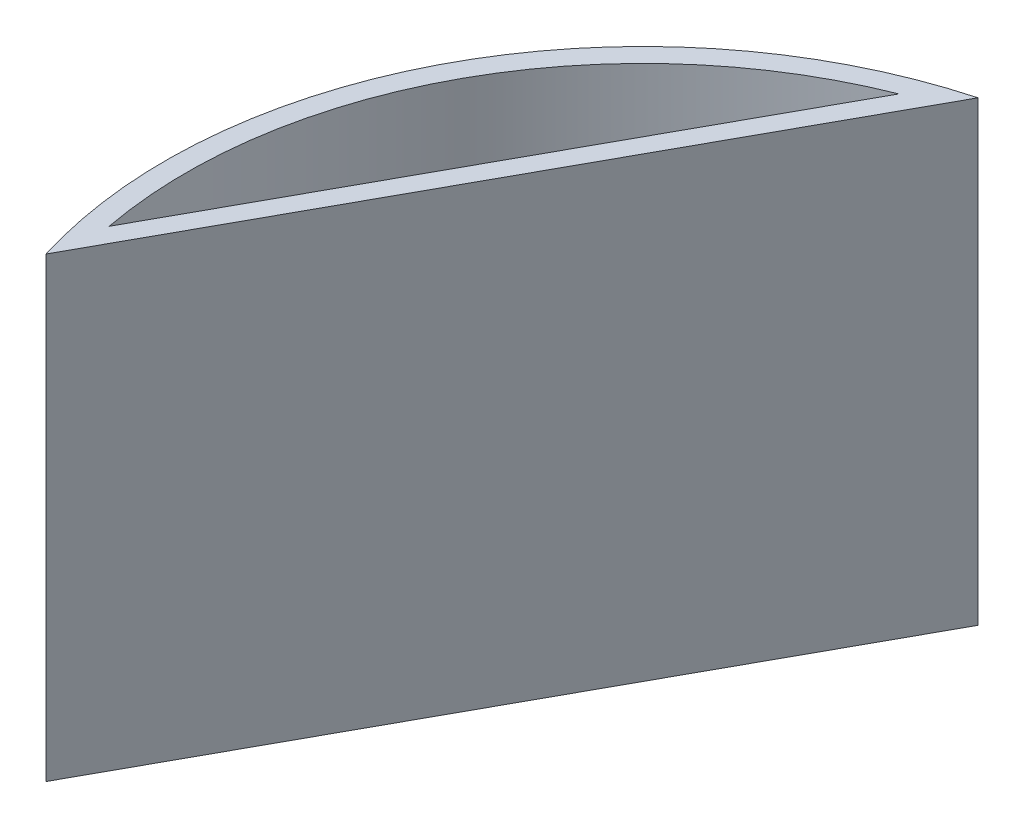
from build123d import *

# Parameters (mm, degrees)
SKETCH1_R               = 73.025
SKETCH1_R_2             = 69.85
BOSS_EXTRUDE1_DEPTH     = 63.5
SKETCH2_R               = 73.025
BOSS_EXTRUDE2_DEPTH     = 6.35
BOSS_EXTRUDE3_DEPTH     = 63.5
CUT_EXTRUDE2_START      = -6.35
CUT_EXTRUDE2_DEPTH      = 6.35
CUT_EXTRUDE2_DEPTH_BACK = 57.15
CUT_EXTRUDE5_DEPTH      = 1016


with BuildPart() as part:
    # Sketch1 → Boss-Extrude1 (new body)
    with BuildSketch(Plane(origin=(0, 0, 0), x_dir=(1, 0, 0), z_dir=(0, 1, 0))):
        Circle(SKETCH1_R)
        Circle(SKETCH1_R_2, mode=Mode.SUBTRACT)
    extrude(amount=BOSS_EXTRUDE1_DEPTH)

    # Sketch2 → Boss-Extrude2 (add)
    with BuildSketch(Plane.XZ):
        Circle(SKETCH2_R)
    extrude(amount=BOSS_EXTRUDE2_DEPTH)

    # Sketch3 → Boss-Extrude3 (add)
    with BuildSketch(Plane(origin=(0, 0, 0), x_dir=(1, 0, 0), z_dir=(0, 1, 0))):
        with BuildLine():
            Line((-67.615293174, -17.526968618), (-21.409243237, 66.488095205))
            ThreePointArc((-21.409243237, 66.488095205), (-61.204368783, 33.660774529), (-67.615293174, -17.526968618))
        make_face()
    extrude(amount=BOSS_EXTRUDE3_DEPTH)

    # Sketch4 → Cut-Extrude2 (cut, two sides)
    with BuildSketch(Plane(origin=(0, 63.5, 0), x_dir=(1, 0, 0), z_dir=(0, 1, 0)).offset(CUT_EXTRUDE2_START)) as cut_extrude2_sk:
        with BuildLine():
            Line((-25.79189716, 64.913793148), (-68.632882923, -12.982676212))
            ThreePointArc((-68.632882923, -12.982676212), (-61.204368783, 33.660774529), (-25.79189716, 64.913793148))
        make_face()
    extrude(amount=CUT_EXTRUDE2_DEPTH, mode=Mode.SUBTRACT)
    extrude(cut_extrude2_sk.sketch, amount=-CUT_EXTRUDE2_DEPTH_BACK, mode=Mode.SUBTRACT)

    # Sketch7 → Cut-Extrude5 (cut)
    with BuildSketch(Plane(origin=(0, 63.5, 0), x_dir=(1, 0, 0), z_dir=(0, 1, 0))):
        Polygon((-72.609628953, -26.608018388), (-10.171407592, 86.921512047), (114.959945388, 65.80584256), (122.548753565, -33.748740716), (41.017949176, -93.980716613), (-75.603403444, -72.676842996), align=None)
    extrude(amount=-CUT_EXTRUDE5_DEPTH, mode=Mode.SUBTRACT)


solid = part.part
